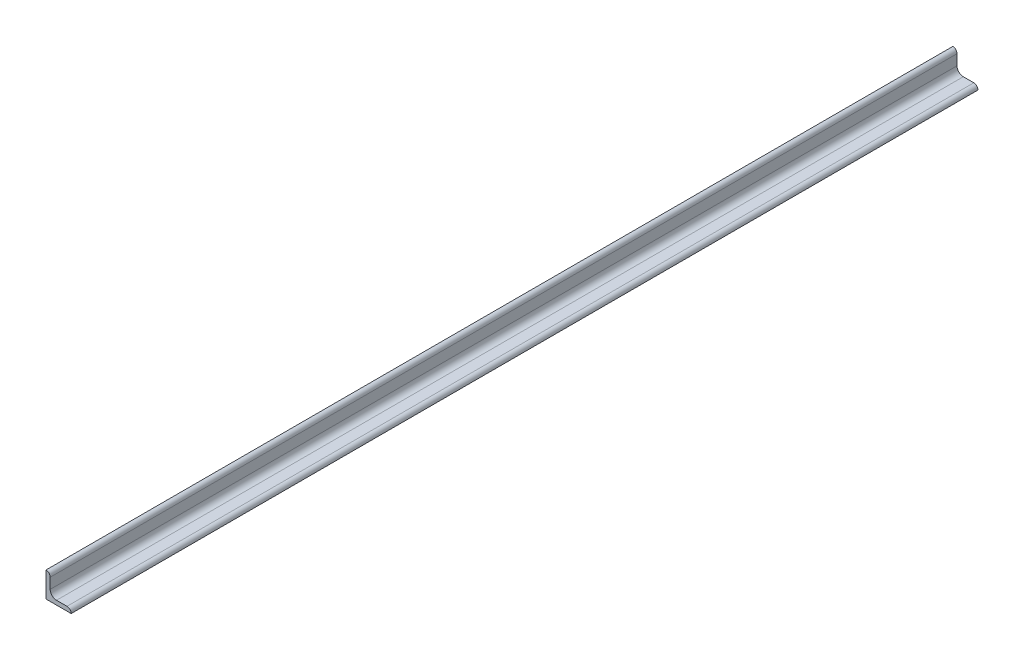
from build123d import *

# Parameters (mm, degrees)
BASESTEELANGLE_DEPTH = 342.9


with BuildPart() as part:
    # Sketch1 → BaseSteelAngle (new body, symmetric)
    with BuildSketch(Plane.XY):
        with BuildLine():
            Line((0, 0), (0, 19.05))
            Line((0, 19.05), (0.00508, 19.05))
            ThreePointArc((0.00508, 19.05), (2.246551928, 18.121551928), (3.175, 15.88008))
            Line((3.175, 15.88008), (3.175, 7.9375))
            ThreePointArc((3.175, 7.9375), (4.569903955, 4.569903955), (7.9375, 3.175))
            Line((7.9375, 3.175), (15.88008, 3.175))
            ThreePointArc((15.88008, 3.175), (18.121551928, 2.246551928), (19.05, 0.00508))
            Line((19.05, 0.00508), (19.05, 0))
            Line((19.05, 0), (0, 0))
        make_face()
    extrude(amount=BASESTEELANGLE_DEPTH, both=True)


solid = part.part
